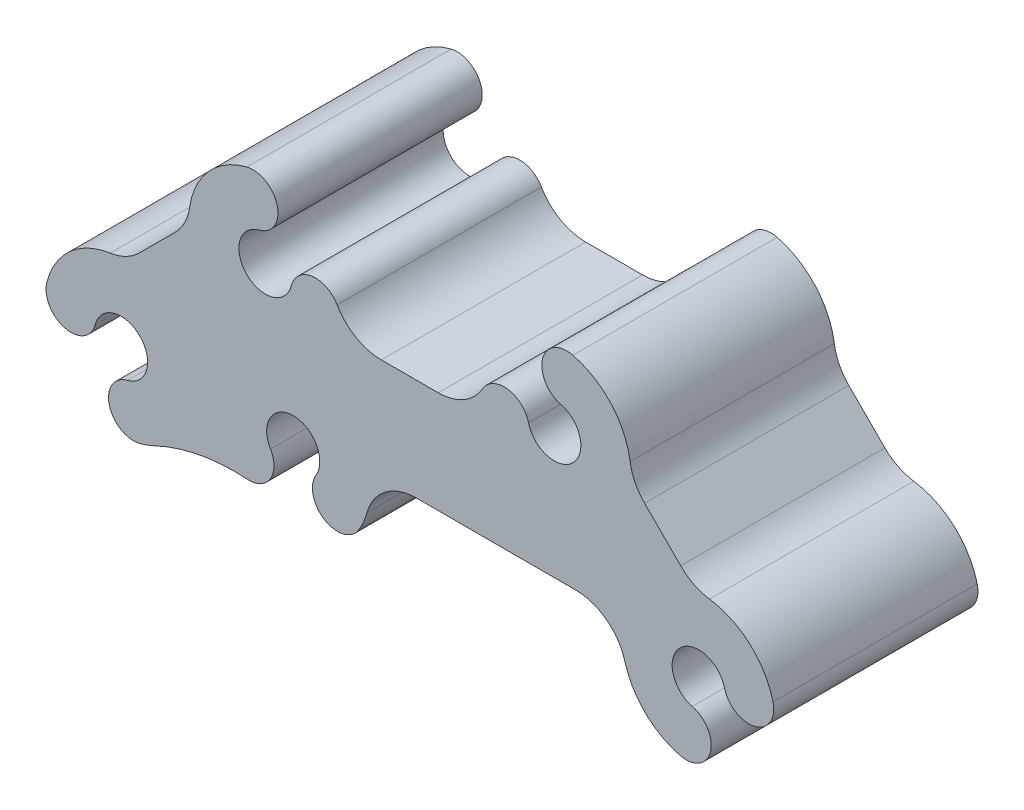
from build123d import *

# Parameters (mm, degrees)
EXTRUDE1_DEPTH = 25.4


with BuildPart() as part:
    # Sketch1 → Extrude1 (new body)
    with BuildSketch(Plane(origin=(0, 0, 0), x_dir=(-1, 0, 0), z_dir=(0, 0, -1))):
        with BuildLine():
            Line((-28.4031636, 13.629935888), (-32.893291852, 9.1398078))
            ThreePointArc((-32.893291852, 9.1398078), (-34.543613516, 7.950323271), (-36.485394142, 7.343756669))
            ThreePointArc((-36.485394142, 7.343756669), (-41.518486911, 4.986937798), (-44.379528747, 0.222375109))
            ThreePointArc((-44.379528747, 0.222375109), (-42.11465539, -3.550317984), (-38.341962297, -1.285444627))
            ThreePointArc((-38.341962297, -1.285444627), (-32.803489024, 0.249354355), (-34.338287977, -5.289118926))
            ThreePointArc((-34.338287977, -5.289118926), (-36.603161315, -9.061812031), (-32.83046821, -11.326685369))
            ThreePointArc((-32.83046821, -11.326685369), (-28.495505008, -8.911796802), (-25.963459646, -4.644205087))
            ThreePointArc((-25.963459646, -4.644205087), (-23.686829805, -1.292614643), (-19.846862338, -3.17e-07))
            Line((-19.846862338, -3.17e-07), (-1.51e-07, -3.17e-07))
            ThreePointArc((-1.51e-07, -3.17e-07), (3.839967369, -1.292614683), (6.116597193, -4.644205214))
            ThreePointArc((6.116597193, -4.644205214), (6.541993463, -5.850068204), (7.125074213, -6.988085944))
            ThreePointArc((7.125074213, -6.988085944), (11.394278391, -8.05427551), (12.460467957, -3.785071333))
            ThreePointArc((12.460467957, -3.785071333), (15.291493211, 1.216487441), (18.122518489, -3.785071355))
            ThreePointArc((18.122518489, -3.785071355), (18.136702605, -7.011479338), (21.004062529, -8.490721154))
            ThreePointArc((21.004062529, -8.490721154), (26.953441296, -8.84329767), (32.619745859, -10.690568776))
            ThreePointArc((32.619745859, -10.690568776), (33.491988235, -11.052706637), (34.39580584, -11.326685338))
            ThreePointArc((34.39580584, -11.326685338), (38.168498974, -9.06181205), (35.903625686, -5.289118916))
            ThreePointArc((35.903625686, -5.289118916), (34.368826811, 0.249354392), (39.907300062, -1.285444686))
            ThreePointArc((39.907300062, -1.285444686), (43.679993114, -3.550318112), (45.94486654, 0.22237494))
            ThreePointArc((45.94486654, 0.22237494), (43.083824747, 4.98693772), (38.05073195, 7.34375666))
            ThreePointArc((38.05073195, 7.34375666), (36.108951241, 7.950323318), (34.458629534, 9.13980795))
            Line((34.458629534, 9.13980795), (29.968501118, 13.62993653))
            ThreePointArc((29.968501118, 13.62993653), (28.779016615, 15.280258142), (28.172450003, 17.222038705))
            ThreePointArc((28.172450003, 17.222038705), (25.815631099, 22.255131366), (21.051068468, 25.116173138))
            ThreePointArc((21.051068468, 25.116173138), (17.278375375, 22.851299781), (19.543248732, 19.078606688))
            ThreePointArc((19.543248732, 19.078606688), (21.078047709, 13.540133409), (15.539574429, 15.074932385))
            ThreePointArc((15.539574429, 15.074932385), (12.952898028, 17.402372212), (9.825816702, 15.876189609))
            ThreePointArc((9.825816702, 15.876189609), (7.501463487, 13.551082107), (4.325868739, 12.7))
            Line((4.325868739, 12.7), (-2.757620705, 12.7))
            ThreePointArc((-2.757620705, 12.7), (-5.934397036, 13.551764634), (-8.258932193, 15.878553656))
            ThreePointArc((-8.258932193, 15.878553656), (-11.386891596, 17.405865193), (-13.973784314, 15.076745914))
            ThreePointArc((-13.973784314, 15.076745914), (-19.51138772, 13.538811919), (-17.979724841, 19.07815315))
            ThreePointArc((-17.979724841, 19.07815315), (-15.716988069, 22.852128084), (-19.490963002, 25.114864856))
            ThreePointArc((-19.490963002, 25.114864856), (-24.252099482, 22.253128677), (-26.607112294, 17.222038418))
            ThreePointArc((-26.607112294, 17.222038418), (-27.213678942, 15.280257647), (-28.4031636, 13.629935888))
        make_face()
    extrude(amount=-EXTRUDE1_DEPTH)


solid = part.part
